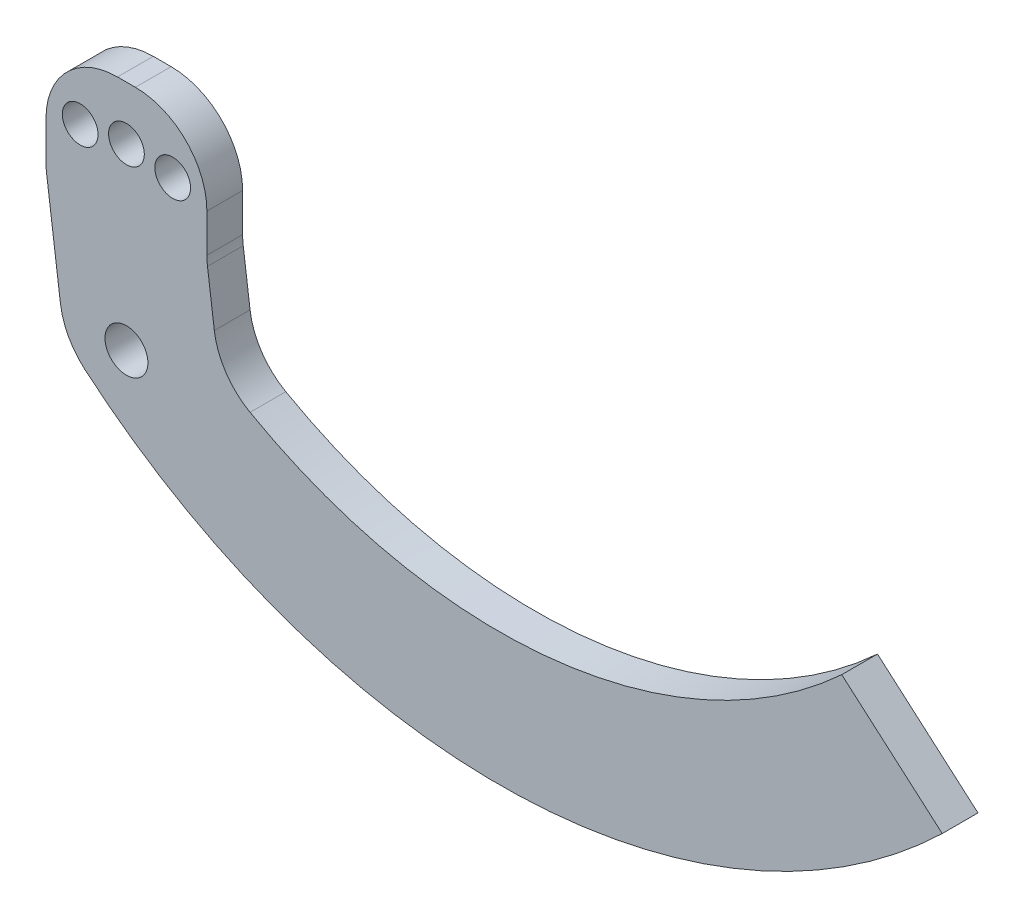
from build123d import *

# Parameters (mm, degrees)
ESQUISSE1_R        = 6
ESQUISSE1_R_2      = 5
BOSS_EXTRU_1_DEPTH = 5
CONG_1_R           = 20


with BuildPart() as part:
    # Esquisse1 → Boss.-Extru.1 (new body, symmetric)
    with BuildSketch(Plane.XY):
        with BuildLine():
            Line((200.083196535, -26.00073282), (228.193277133, -50.436453083))
            ThreePointArc((228.193277133, -50.436453083), (105.798406768, -100.555368837), (-17.5, -52.702334489))
            Line((-17.5, -52.702334489), (-22.5, -14.5))
            Line((-22.5, -14.5), (-22.5, 17.5))
            Line((-22.5, 17.5), (22.5, 17.5))
            Line((22.5, 17.5), (22.5, -14.5))
            Line((22.5, -14.5), (25.81470592, -39.825900861))
            ThreePointArc((25.81470592, -39.825900861), (115.339933121, -63.052032289), (200.083196535, -26.00073282))
        make_face()
        with Locations((0, -47.5)):
            Circle(ESQUISSE1_R, mode=Mode.SUBTRACT)
        with Locations((-12.940952255, 0.796291314)):
            Circle(ESQUISSE1_R_2, mode=Mode.SUBTRACT)
        with Locations((0, 2.5)):
            Circle(ESQUISSE1_R_2, mode=Mode.SUBTRACT)
        with Locations((12.940952255, 0.796291314)):
            Circle(ESQUISSE1_R_2, mode=Mode.SUBTRACT)
    extrude(amount=BOSS_EXTRU_1_DEPTH, both=True)

    # Congé1
    cong_1_edges = [part.edges().sort_by_distance(p)[0] for p in [
        (-17.5, -52.702334489, 0),
        (-22.5, -14.5, 0),
        (-22.5, 17.5, 0),
        (22.5, 17.5, 0),
        (22.5, -14.5, 0),
        (25.81470592, -39.825900861, 0),
    ]]
    fillet(cong_1_edges, radius=CONG_1_R)


solid = part.part
